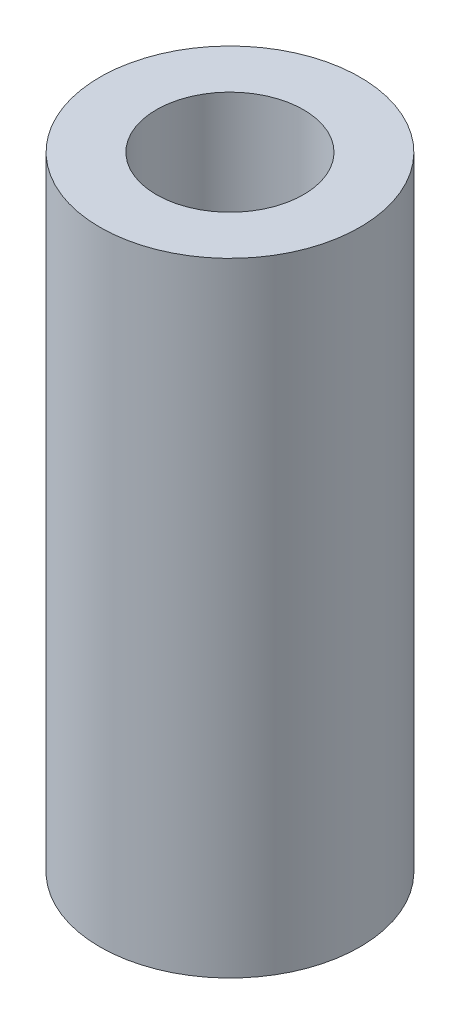
from build123d import *

# Parameters (mm, degrees)
SKETCH2_R            = 3.9751
BOSS_EXTRUDE1_DEPTH  = 9.525
M4_CLEARANCE_HOLE1_D = 4.5


with BuildPart() as part:
    # Sketch2 → Boss-Extrude1 (new body, symmetric)
    with BuildSketch(Plane(origin=(0, 0, 0), x_dir=(1, 0, 0), z_dir=(0, 1, 0))):
        Circle(SKETCH2_R)
    extrude(amount=BOSS_EXTRUDE1_DEPTH, both=True)

    # M4 Clearance Hole1 (through all)
    with Locations(Plane(origin=(0, 9.525, 0), x_dir=(1, 0, 0), z_dir=(0, 1, 0))):
        with Locations((0, 0)):
            Hole(M4_CLEARANCE_HOLE1_D / 2)


solid = part.part
